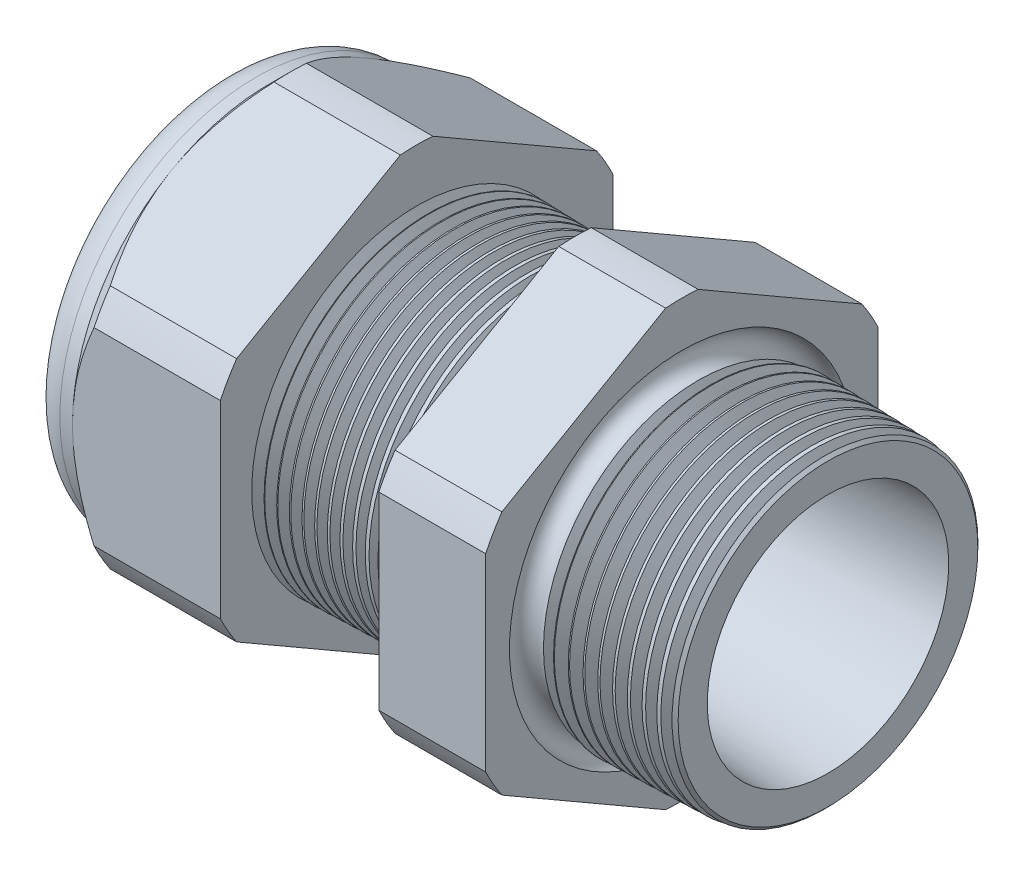
from build123d import *

# Parameters (mm, degrees)
SKETCH12_OUTSIDE_W = 65.136
SKETCH12_OUTSIDE_H = 65.136
CUT_EXTRUDE2_DEPTH = 35.03
FILLET4_R          = 2.032
SKETCH19_OUTSIDE_W = 40.13
SKETCH19_OUTSIDE_H = 42.756
SKETCH19_OUTSIDE_R = 11.938
CUT_EXTRUDE3_DEPTH = 1.999996
CUT_EXTRUDE3_DRAFT = -45
CHAMFER1_SIZE      = 0.260919487
CHAMFER1_SIZE2     = 0.254
SKETCH21_R         = 5.969
PLUG_DEPTH         = 6.35
SKETCH22_R         = 5.715
CUT_EXTRUDE4_DEPTH = 0.508
SKETCH27_R         = 1.524
PLUGHOLES_DEPTH    = 37.322
CIRPATTERN1_COUNT  = 4
LPATTERN1_COUNT    = 13
LPATTERN1_PITCH    = 0.762
LPATTERN2_COUNT    = 10
LPATTERN2_PITCH    = 0.889
SKETCH32_R         = 0.889


with BuildPart() as part:
    # Sketch10 → Revolve2 (revolve)
    with BuildSketch(Plane.XY, mode=Mode.PRIVATE) as revolve2_sk:
        Polygon((-35.814, 5.969), (-24.014, 5.969), (1.016, 7.345566383), (1.016, 9.377566383), (-7.874, 9.610359226), (-7.874, 23.876), (-14.374, 23.876), (-14.374, 9.780567716), (-24.014, 10.033), (-24.014, 23.876), (-33.014, 23.876), (-33.014, 11.938), (-35.814, 11.938), align=None)
    revolve(revolve2_sk.sketch.rotate(Axis((0, 0, 0), (-1, 0, 0)), 90), axis=Axis((0, 0, 0), (-1, 0, 0)))  # turned: the seam where the file's is

    # Sketch12 outside → Cut-Extrude2 (cut, through all)
    with BuildSketch(Plane.ZY.offset(33.014)):
        Rectangle(SKETCH12_OUTSIDE_W, SKETCH12_OUTSIDE_H)
        with BuildLine():
            Line((-0.98819228, 13.214281948), (-10.94980772, 7.462940592))
            ThreePointArc((-10.94980772, 7.462940592), (-11.47585851, 6.62559), (-11.938, 5.751341356))
            Line((-11.938, 5.751341356), (-11.938, -5.751341356))
            ThreePointArc((-11.938, -5.751341356), (-11.47585851, -6.62559), (-10.94980772, -7.462940592))
            Line((-10.94980772, -7.462940592), (-0.98819228, -13.214281948))
            ThreePointArc((-0.98819228, -13.214281948), (0, -13.25118), (0.98819228, -13.214281948))
            Line((0.98819228, -13.214281948), (10.94980772, -7.462940592))
            ThreePointArc((10.94980772, -7.462940592), (11.47585851, -6.62559), (11.938, -5.751341356))
            Line((11.938, -5.751341356), (11.938, 5.751341356))
            ThreePointArc((11.938, 5.751341356), (11.47585851, 6.62559), (10.94980772, 7.462940592))
            Line((10.94980772, 7.462940592), (0.98819228, 13.214281948))
            ThreePointArc((0.98819228, 13.214281948), (0, 13.25118), (-0.98819228, 13.214281948))
        make_face(mode=Mode.SUBTRACT)
    extrude(amount=-CUT_EXTRUDE2_DEPTH, mode=Mode.SUBTRACT)

    # Fillet4
    fillet4_edges = [part.edges().sort_by_distance(p)[0] for p in [
        (-35.814, 0, 11.938),
    ]]
    fillet(fillet4_edges, radius=FILLET4_R)


with BuildPart() as cut_extrude3_tool:
    # Sketch19 outside → Cut-Extrude3 (with draft: the straight prism first)
    with BuildSketch(Plane.ZY.offset(33.014)):
        Rectangle(SKETCH19_OUTSIDE_W, SKETCH19_OUTSIDE_H)
        Circle(SKETCH19_OUTSIDE_R, mode=Mode.SUBTRACT)
    extrude(amount=-CUT_EXTRUDE3_DEPTH)
    # Cut-Extrude3: the draft: its side faces are tilted about the plane it starts from
    cut_extrude3_sides = [cut_extrude3_tool.faces().sort_by_distance(p)[0] for p in [
        (-32.014002, -21.378, 0),
        (-32.014002, 0, 20.065),
        (-32.014002, 21.378, 0),
        (-32.014002, 0, -20.065),
        (-32.014002, 0, -11.938),
    ]]
    draft(cut_extrude3_sides, Plane.ZY.offset(33.014), CUT_EXTRUDE3_DRAFT)


with BuildPart() as part_1:
    add(part.part)

    # Cut-Extrude3: cut by cut_extrude3_tool
    add(cut_extrude3_tool.part, mode=Mode.SUBTRACT)

    # Chamfer1
    chamfer1_edges = [part_1.edges().sort_by_distance(p)[0] for p in [
        (1.016, 0, 9.377566383),
    ]]
    chamfer1_side = [part_1.faces().sort_by_distance(p)[0] for p in [
        (1.016, 0, 7.610804014),
    ]]
    chamfer(chamfer1_edges, length=CHAMFER1_SIZE, length2=CHAMFER1_SIZE2, reference=chamfer1_side[0])

    # Sketch29 → Cut-Revolve1 (revolve, cut)
    with BuildSketch(Plane.XY, mode=Mode.PRIVATE) as cut_revolve1_sk:
        Polygon((-24.014, 10.033), (-23.281016419, 10.013806149), (-23.664130572, 9.388620673), align=None)
    cut_revolve1 = revolve(cut_revolve1_sk.sketch.rotate(Axis((0, 0, 0), (-1, 0, 0)), 90), axis=Axis((0, 0, 0), (-1, 0, 0)), mode=Mode.SUBTRACT)  # turned: the seam where the file's is

    # LPattern1: Cut-Revolve1 ×13
    with Locations(*[(i * LPATTERN1_PITCH, 0, 0) for i in range(1, LPATTERN1_COUNT)]):
        add(cut_revolve1, mode=Mode.SUBTRACT)

    # Sketch30 → Cut-Revolve2 (revolve, cut)
    with BuildSketch(Plane.XY, mode=Mode.PRIVATE) as cut_revolve2_sk:
        Polygon((-7.874, 9.610359226), (-6.994419703, 9.587326605), (-7.454156686, 8.837104034), align=None)
    cut_revolve2 = revolve(cut_revolve2_sk.sketch.rotate(Axis((0, 0, 0), (-1, 0, 0)), 270), axis=Axis((0, 0, 0), (-1, 0, 0)), mode=Mode.SUBTRACT)  # turned: the seam where the file's is

    # LPattern2: Cut-Revolve2 ×10
    with Locations(*[(i * LPATTERN2_PITCH, 0, 0) for i in range(1, LPATTERN2_COUNT)]):
        add(cut_revolve2, mode=Mode.SUBTRACT)

    # Sketch32 → Cut-Revolve3 (revolve, cut)
    with BuildSketch(Plane.XY, mode=Mode.PRIVATE) as cut_revolve3_sk:
        with Locations((-7.747, 9.610359226)):
            Circle(SKETCH32_R)
    revolve(cut_revolve3_sk.sketch.rotate(Axis((0, 0, 0), (-1, 0, 0)), 270), axis=Axis((0, 0, 0), (-1, 0, 0)), mode=Mode.SUBTRACT)  # turned: the seam where the file's is


with BuildPart() as body_2:
    # Sketch21 → plug (new body)
    with BuildSketch(Plane.ZY.offset(35.814)):
        Circle(SKETCH21_R)
    extrude(amount=-PLUG_DEPTH)

    # Sketch22 → Cut-Extrude4 (cut)
    with BuildSketch(Plane.ZY.offset(35.814)):
        Circle(SKETCH22_R)
    extrude(amount=-CUT_EXTRUDE4_DEPTH, mode=Mode.SUBTRACT)

    # Sketch27 → plugholes (cut, through all)
    with BuildSketch(Plane.ZY.offset(35.306)):
        with Locations((-4.184904, 0)):
            Circle(SKETCH27_R)
    plugholes = extrude(amount=-PLUGHOLES_DEPTH, mode=Mode.SUBTRACT)

    # CirPattern1: plugholes ×4 about axis
    cirpattern1_axis = Axis((0, 0, 0), (1, 0, 0))
    for i in range(1, CIRPATTERN1_COUNT):
        add(plugholes.rotate(cirpattern1_axis, i * 360 / CIRPATTERN1_COUNT), mode=Mode.SUBTRACT)


solid = Compound([part_1.part, body_2.part])
